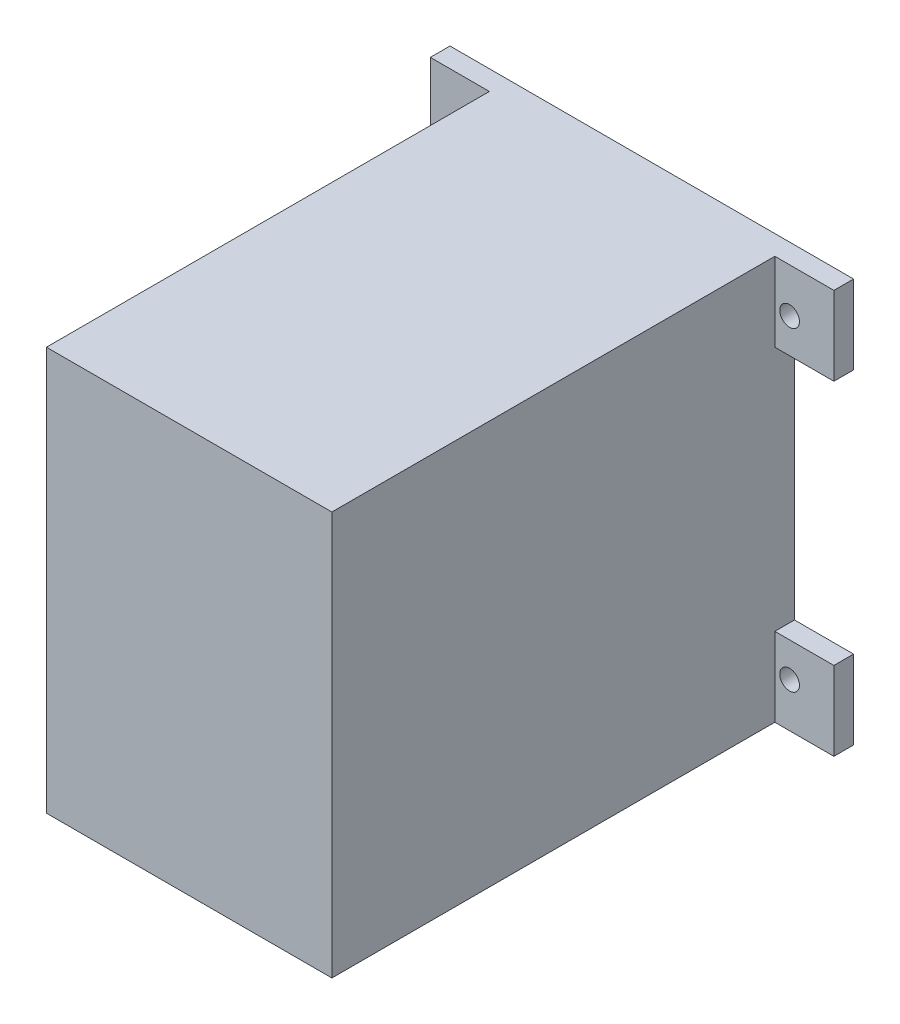
from build123d import *

# Parameters (mm, degrees)
SKETCH_1_W          = 29
SKETCH_1_H          = 41
EXTRUDE_1_DEPTH     = 47
SKETCH_2_W          = 26.5
SKETCH_2_H          = 38.5
CUT_EXTRUDE_1_DEPTH = 46
SKETCH_4_W          = 6
SKETCH_4_H          = 8
EXTRUDE_2_DEPTH     = 2
SKETCH_5_R          = 1
CUT_EXTRUDE_4_DEPTH = 2


with BuildPart() as part:
    # ｽｹｯﾁ1 → ﾎﾞｽ - 押し出し1 (new body)
    with BuildSketch(Plane.XY):
        Rectangle(SKETCH_1_W, SKETCH_1_H)
    extrude(amount=EXTRUDE_1_DEPTH)

    # ｽｹｯﾁ2 → ｶｯﾄ - 押し出し1 (cut)
    with BuildSketch(Plane.XY):
        Rectangle(SKETCH_2_W, SKETCH_2_H)
    extrude(amount=CUT_EXTRUDE_1_DEPTH, mode=Mode.SUBTRACT)

    # ｽｹｯﾁ4 → ﾎﾞｽ - 押し出し2 (add)
    with BuildSketch(Plane.XY):
        with Locations((17.5, 16.5)):
            Rectangle(SKETCH_4_W, SKETCH_4_H)
        with Locations((17.5, -16.5)):
            Rectangle(SKETCH_4_W, SKETCH_4_H)
        with Locations((-17.5, -16.5)):
            Rectangle(SKETCH_4_W, SKETCH_4_H)
        with Locations((-17.5, 16.5)):
            Rectangle(SKETCH_4_W, SKETCH_4_H)
    extrude(amount=EXTRUDE_2_DEPTH)

    # ｽｹｯﾁ5 → ｶｯﾄ - 押し出し4 (cut)
    with BuildSketch(Plane.XY):
        with Locations((-16, 16)):
            Circle(SKETCH_5_R)
        with Locations((-16, -16)):
            Circle(SKETCH_5_R)
        with Locations((16, -16)):
            Circle(SKETCH_5_R)
        with Locations((16, 16)):
            Circle(SKETCH_5_R)
    extrude(amount=CUT_EXTRUDE_4_DEPTH, mode=Mode.SUBTRACT)


solid = part.part
